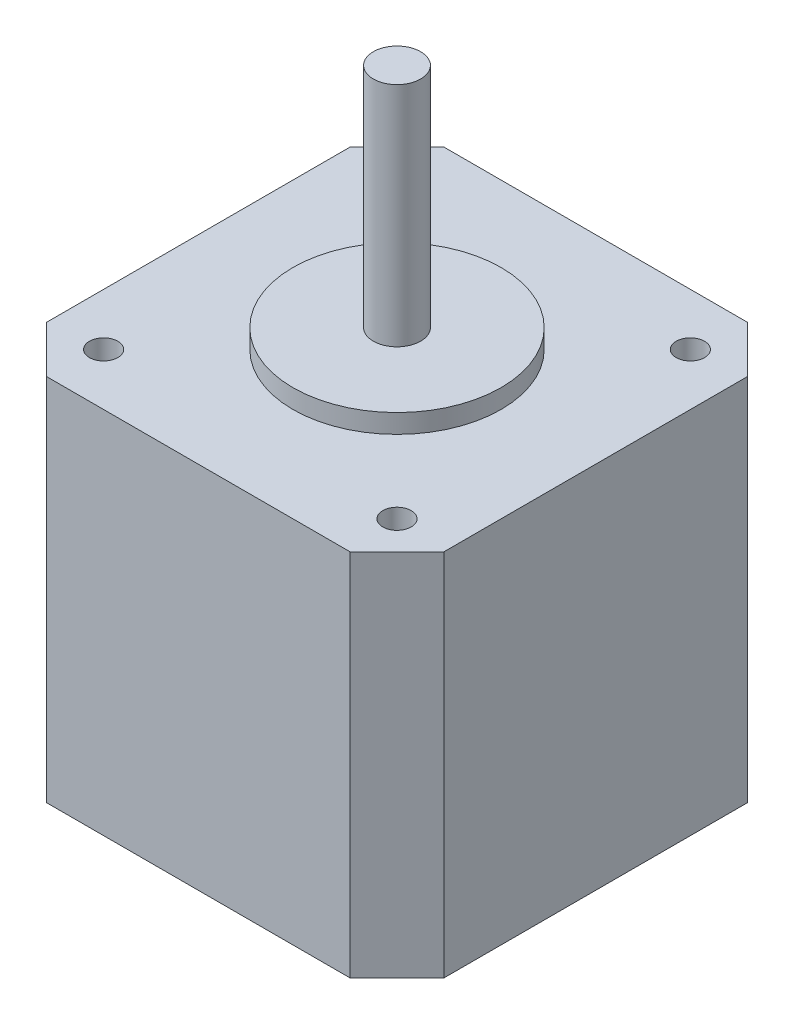
from build123d import *

# Parameters (mm, degrees)
SKETCH1_W           = 42
SKETCH1_H           = 42
BOSS_EXTRUDE1_DEPTH = 39
SKETCH5_R           = 11
BOSS_EXTRUDE4_DEPTH = 2
SKETCH6_R           = 2.5
BOSS_EXTRUDE5_DEPTH = 24
SKETCH8_R           = 1.5
CUT_EXTRUDE1_DEPTH  = 4.5
CUT_EXTRUDE2_DEPTH  = 40


with BuildPart() as part:
    # Sketch1 → Boss-Extrude1 (new body)
    with BuildSketch(Plane(origin=(0, 0, 0), x_dir=(1, 0, 0), z_dir=(0, 1, 0))):
        with Locations((21, 21)):
            Rectangle(SKETCH1_W, SKETCH1_H)
    extrude(amount=BOSS_EXTRUDE1_DEPTH)

    # Sketch5 → Boss-Extrude4 (add)
    with BuildSketch(Plane(origin=(0, 39, 0), x_dir=(1, 0, 0), z_dir=(0, 1, 0))):
        with Locations((21, 21)):
            Circle(SKETCH5_R)
    extrude(amount=BOSS_EXTRUDE4_DEPTH)

    # Sketch6 → Boss-Extrude5 (add)
    with BuildSketch(Plane(origin=(0, 41, 0), x_dir=(1, 0, 0), z_dir=(0, 1, 0))):
        with Locations((21, 21)):
            Circle(SKETCH6_R)
    extrude(amount=BOSS_EXTRUDE5_DEPTH)

    # Sketch8 → Cut-Extrude1 (cut)
    with BuildSketch(Plane(origin=(0, 39, 0), x_dir=(1, 0, 0), z_dir=(0, 1, 0))):
        with Locations((36.5, 5.5)):
            Circle(SKETCH8_R)
        with Locations((36.5, 36.5)):
            Circle(SKETCH8_R)
        with Locations((5.5, 5.5)):
            Circle(SKETCH8_R)
        with Locations((5.5, 36.5)):
            Circle(SKETCH8_R)
    extrude(amount=-CUT_EXTRUDE1_DEPTH, mode=Mode.SUBTRACT)

    # Sketch9 → Cut-Extrude2 (cut, through all)
    with BuildSketch(Plane(origin=(0, 39, 0), x_dir=(1, 0, 0), z_dir=(0, 1, 0))):
        Polygon((0, 4.949747468), (4.949747468, 0), (0, 0), align=None)
        Polygon((37.050252532, 0), (42, 4.949747468), (42, 0), align=None)
        Polygon((37.050252532, 42), (42, 37.050252532), (42, 42), align=None)
        Polygon((0, 37.050252532), (4.949747468, 42), (0, 42), align=None)
    extrude(amount=-CUT_EXTRUDE2_DEPTH, mode=Mode.SUBTRACT)


solid = part.part
